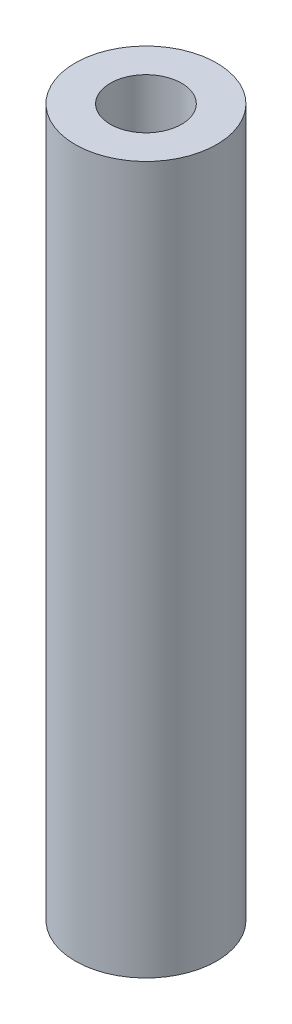
from build123d import *

# Parameters (mm, degrees)
SKETCH1_R           = 6.35
SKETCH1_R_2         = 3.2004
BOSS_EXTRUDE1_DEPTH = 63.5


with BuildPart() as part:
    # Sketch1 → Boss-Extrude1 (new body)
    with BuildSketch(Plane(origin=(0, 0, 0), x_dir=(1, 0, 0), z_dir=(0, 1, 0))):
        Circle(SKETCH1_R)
        Circle(SKETCH1_R_2, mode=Mode.SUBTRACT)
    extrude(amount=BOSS_EXTRUDE1_DEPTH)


solid = part.part
